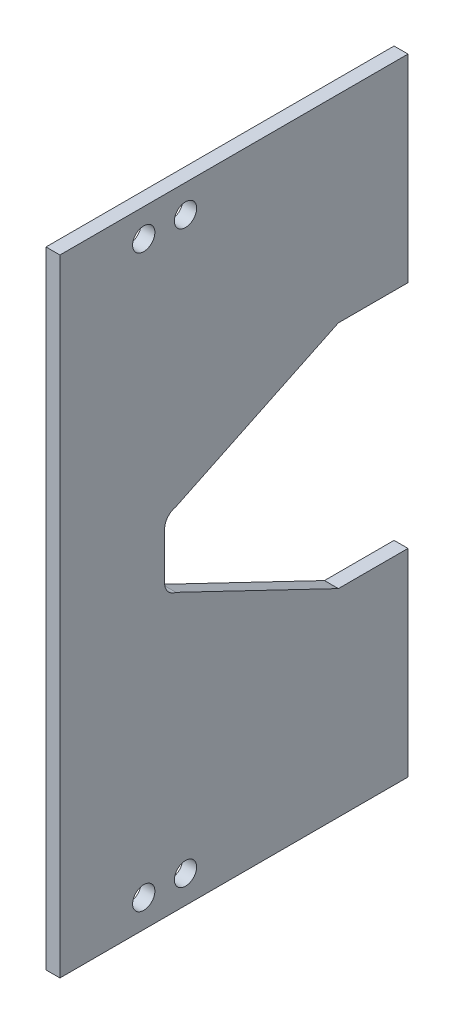
from build123d import *

# Parameters (mm, degrees)
EXTRUDE_1_DEPTH     = 2
FILLET_1_R          = 2
FILLET_2_R          = 2
FILLET_3_R          = 2
FILLET_4_R          = 2
SKETCH_2_W          = 12
SKETCH_2_H          = 89.95
EXTRUDE_2_DEPTH     = 2
CUT_EXTRUDE_1_DEPTH = 10
SKETCH_7_R          = 1.6
CUT_EXTRUDE_2_DEPTH = 10
SKETCH_8_W          = 10
SKETCH_8_H          = 28.446825321
EXTRUDE_3_DEPTH     = 2


with BuildPart() as part:
    # 草图1 → 凸台-拉伸1 (new body)
    with BuildSketch(Plane(origin=(-0.79375, 0, 0), x_dir=(0, -1, 0), z_dir=(-1, 0, 0))):
        with BuildLine():
            Line((38.795, 5), (12.795, 5))
            ThreePointArc((12.795, 5), (11.380786438, 4.414213562), (10.795, 3))
            Line((10.795, 3), (10.795, -13))
            ThreePointArc((10.795, -13), (11.380786438, -14.414213562), (12.795, -15))
            Line((12.795, -15), (47.795, -15))
            Line((47.795, -15), (50.77, -0.039144756))
            Line((50.77, -0.039144756), (55.77, -0.039144756))
            Line((55.77, -0.039144756), (60.77, -0.039144756))
            Line((60.77, -0.039144756), (63.745, -15))
            Line((63.745, -15), (98.745, -15))
            ThreePointArc((98.745, -15), (100.159213562, -14.414213562), (100.745, -13))
            Line((100.745, -13), (100.745, 3))
            ThreePointArc((100.745, 3), (100.159213562, 4.414213562), (98.745, 5))
            Line((98.745, 5), (72.745, 5))
            Line((72.745, 5), (38.795, 5))
        make_face()
    extrude(amount=-EXTRUDE_1_DEPTH)

    # 圆角1
    fillet_1_edges = [part.edges().sort_by_distance(p)[0] for p in [
        (0.20625, -50.77, -0.039144756),
    ]]
    fillet(fillet_1_edges, radius=FILLET_1_R)

    # 圆角2
    fillet_2_edges = [part.edges().sort_by_distance(p)[0] for p in [
        (0.20625, -47.795, -15),
    ]]
    fillet(fillet_2_edges, radius=FILLET_2_R)

    # 圆角3
    fillet_3_edges = [part.edges().sort_by_distance(p)[0] for p in [
        (0.20625, -60.77, -0.039144756),
    ]]
    fillet(fillet_3_edges, radius=FILLET_3_R)

    # 圆角4
    fillet_4_edges = [part.edges().sort_by_distance(p)[0] for p in [
        (0.20625, -63.745, -15),
    ]]
    fillet(fillet_4_edges, radius=FILLET_4_R)

    # 草图2 → 凸台-拉伸2 (add)
    with BuildSketch(Plane.ZY.offset(0.79375)):
        with Locations((9, -55.77)):
            Rectangle(SKETCH_2_W, SKETCH_2_H)
        Polygon((-25, -10.795), (-25, -45.806477318), (-13.39006724, -48.115138781), (-13, -10.795), align=None)
        Polygon((-13.39006724, -63.424861219), (-25, -65.733522682), (-25, -100.745), (-13, -100.745), align=None)
    extrude(amount=-EXTRUDE_2_DEPTH)

    # 草图5 → 切除-拉伸1 (cut)
    with BuildSketch(Plane(origin=(1.20625, 0, 0), x_dir=(0, 0, -1), z_dir=(1, 0, 0))):
        Polygon((1.649077515, -50.449861219), (25, -45.806477318), (25, -39.241825321), align=None)
        Polygon((25, -72.298174679), (25, -65.733522682), (1.649077515, -61.090138781), align=None)
    extrude(amount=-CUT_EXTRUDE_1_DEPTH, mode=Mode.SUBTRACT)

    # 草图7 → 切除-拉伸2 (cut)
    with BuildSketch(Plane(origin=(1.20625, 0, 0), x_dir=(0, 0, -1), z_dir=(1, 0, 0))):
        with Locations((-2.960855244, -14.795)):
            Circle(SKETCH_7_R)
        with Locations((3.039144756, -14.795)):
            Circle(SKETCH_7_R)
        with Locations((3.039144756, -96.745)):
            Circle(SKETCH_7_R)
        with Locations((-2.960855244, -96.745)):
            Circle(SKETCH_7_R)
    extrude(amount=-CUT_EXTRUDE_2_DEPTH, mode=Mode.SUBTRACT)

    # 草图8 → 凸台-拉伸3 (add)
    with BuildSketch(Plane.ZY.offset(0.79375)):
        with Locations((-30, -25.018412661)):
            Rectangle(SKETCH_8_W, SKETCH_8_H)
        with Locations((-30, -86.52158734)):
            Rectangle(SKETCH_8_W, SKETCH_8_H)
    extrude(amount=-EXTRUDE_3_DEPTH)


solid = part.part
